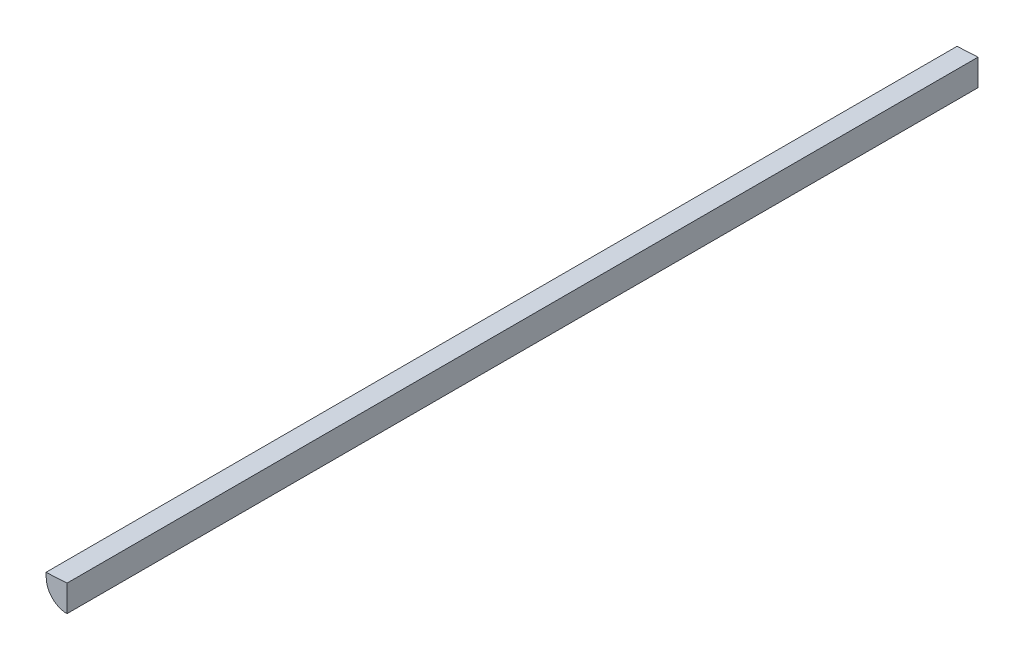
from build123d import *

# Parameters (mm, degrees)
BOSS_EXTRUDE1_DEPTH = 550


with BuildPart() as part:
    # Sketch2 → Boss-Extrude1 (new body)
    with BuildSketch(Plane.XY):
        with BuildLine():
            Line((0, 0), (0, -12.5))
            ThreePointArc((0, -12.5), (-8.604432196, -9.067179638), (-12.482869184, -0.654199453))
            Line((-12.482869184, -0.654199453), (-12.664998312, 2.821031328))
            Line((-12.664998312, 2.821031328), (0, 3.484775764))
            Line((0, 3.484775764), (0, 0))
        make_face()
    extrude(amount=BOSS_EXTRUDE1_DEPTH)


solid = part.part
